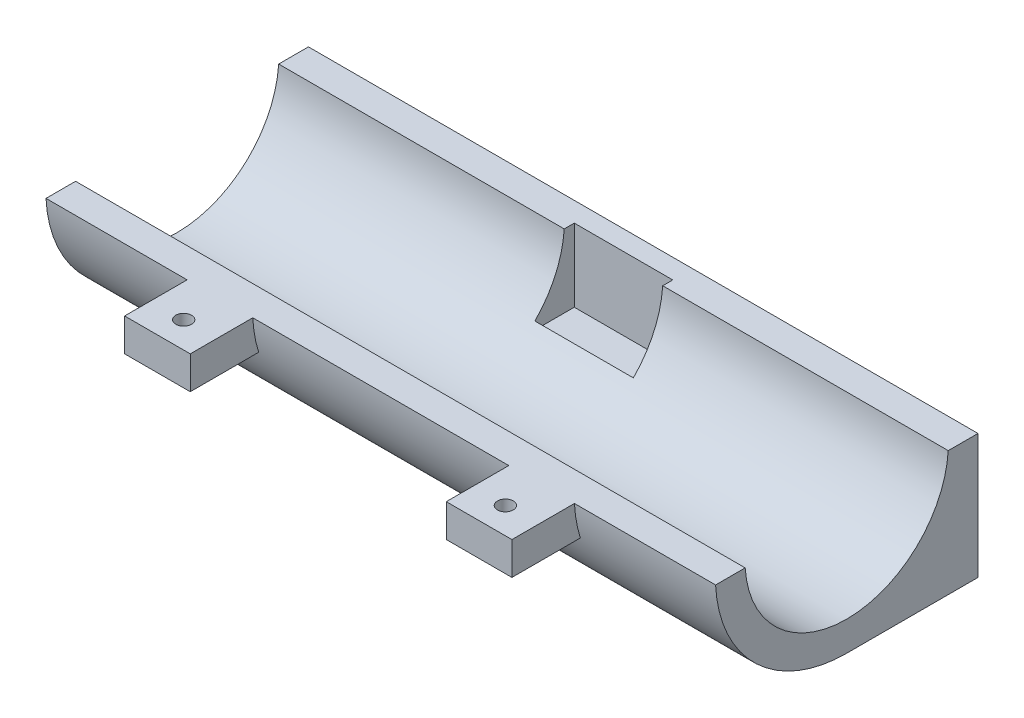
from build123d import *
from build123d.topology import SkipClean

# Parameters (mm, degrees)
SKETCH1_W                = 34
SKETCH1_H                = 30
BOSS_EXTRUDE2_DEPTH      = 51
SKETCH3_R                = 2.55
CUT_EXTRUDE3_DEPTH       = 10
SKETCH5_R                = 7.75
CUT_EXTRUDE4_DEPTH       = 51
SKETCH6_W                = 7
SKETCH6_H                = 30
CUT_EXTRUDE6_DEPTH       = 51
CUT_EXTRUDE7_DEPTH       = 51
CUT_EXTRUDE9_DEPTH       = 1.5
CUT_EXTRUDE9_DEPTH_BACK  = 1.5
BOSS_EXTRUDE5_DEPTH      = 51
CUT_EXTRUDE10_DEPTH      = 13
CUT_EXTRUDE11_START      = -13
CUT_EXTRUDE11_DEPTH      = 13
SKETCH13_W               = 2
SKETCH13_H               = 6
CUT_EXTRUDE12_DEPTH      = 2
CUT_EXTRUDE13_DEPTH      = 13
CUT_EXTRUDE13_DEPTH_BACK = 11
BOSS_EXTRUDE6_DEPTH      = 2.25
BOSS_EXTRUDE7_DEPTH      = 2.25
BOSS_EXTRUDE8_DEPTH      = 2.25
BOSS_EXTRUDE9_DEPTH      = 2.25
SKETCH22_W               = 5
SKETCH22_H               = 6
BOSS_EXTRUDE10_DEPTH     = 1
SKETCH24_W               = 5
SKETCH24_H               = 6
BOSS_EXTRUDE11_DEPTH     = 1
SKETCH25_R               = 0.6
CUT_EXTRUDE14_DEPTH      = 20
SKETCH26_R               = 2.55
BOSS_EXTRUDE12_DEPTH     = 1.5
CUT_EXTRUDE16_DEPTH      = 60


with BuildPart() as part:
    # Sketch1 → Boss-Extrude2 (new body)
    with BuildSketch(Plane(origin=(0, 0, 0), x_dir=(0, 0, -1), z_dir=(1, 0, 0))):
        with Locations((-3.945183177, 6.145902028)):
            Rectangle(SKETCH1_W, SKETCH1_H)
    extrude(amount=BOSS_EXTRUDE2_DEPTH)

    # Sketch3 → Cut-Extrude3 (cut)
    with BuildSketch(Plane(origin=(0, 0, -13.054816823), x_dir=(-1, 0, 0), z_dir=(0, 0, -1))):
        with Locations((-25.5, -1.354097972)):
            Circle(SKETCH3_R)
    extrude(amount=-CUT_EXTRUDE3_DEPTH, mode=Mode.SUBTRACT)

    # Sketch5 → Cut-Extrude4 (cut)
    with BuildSketch(Plane(origin=(51, 0, 0), x_dir=(0, 0, -1), z_dir=(1, 0, 0))):
        with Locations((-3.945183177, 1.145902028)):
            Circle(SKETCH5_R)
    extrude(amount=-CUT_EXTRUDE4_DEPTH, mode=Mode.SUBTRACT)

    # Sketch6 → Cut-Extrude6 (cut)
    with BuildSketch(Plane(origin=(51, 0, 0), x_dir=(0, 0, -1), z_dir=(1, 0, 0))):
        with Locations((9.554816823, 6.145902028)):
            Rectangle(SKETCH6_W, SKETCH6_H)
    extrude(amount=-CUT_EXTRUDE6_DEPTH, mode=Mode.SUBTRACT)

    # Sketch7 → Cut-Extrude7 (cut)
    with BuildSketch(Plane(origin=(51, 0, 0), x_dir=(0, 0, -1), z_dir=(1, 0, 0))):
        with BuildLine():
            Line((-3.945183177, -8.854097972), (-20.945183177, -8.854097972))
            Line((-20.945183177, -8.854097972), (-20.945183177, 21.145902028))
            Line((-20.945183177, 21.145902028), (6.054816823, 21.145902028))
            Line((6.054816823, 21.145902028), (6.054816823, 1.145902028))
            ThreePointArc((6.054816823, 1.145902028), (-11.016250989, 8.21696984), (-3.945183177, -8.854097972))
        make_face()
    extrude(amount=-CUT_EXTRUDE7_DEPTH, mode=Mode.SUBTRACT)

    # Sketch8 → Cut-Extrude9 (cut, two sides: drawn at the far end of the back side and taken through both)
    with BuildSketch(Plane(origin=(0, 0, -3.054816823), x_dir=(-1, 0, 0), z_dir=(0, 0, -1)).offset(-CUT_EXTRUDE9_DEPTH_BACK)):
        Polygon((-21.75, -2.180131646), (-21.75, -4.904097972), (-29.25, -4.904097972), (-29.25, -2.180131646), (-29.25, 2.195902028), (-21.75, 2.195902028), align=None)
    extrude(amount=CUT_EXTRUDE9_DEPTH + CUT_EXTRUDE9_DEPTH_BACK, mode=Mode.SUBTRACT)

    # Sketch10 → Boss-Extrude5 (add)
    with BuildSketch(Plane(origin=(51, 0, 0), x_dir=(0, 0, -1), z_dir=(1, 0, 0))):
        Polygon((-17.695183177, 1.145902028), (-17.695183177, 4.145902028), (-11.695183177, 4.145902028), (-11.695183177, 1.145902028), (-11.695183177, -1.854097972), (-17.695183177, -1.854097972), align=None)
    extrude(amount=-BOSS_EXTRUDE5_DEPTH)

    # Sketch11 → Cut-Extrude10 (cut)
    with BuildSketch(Plane(origin=(51, 0, 0), x_dir=(0, 0, -1), z_dir=(1, 0, 0))):
        with BuildLine():
            Line((-13.484575191, -1.854097972), (-17.695183177, -1.854097972))
            Line((-17.695183177, -1.854097972), (-17.695183177, 4.145902028))
            Line((-17.695183177, 4.145902028), (-13.484575191, 4.145902028))
            ThreePointArc((-13.484575191, 4.145902028), (-13.945183177, 1.145902028), (-13.484575191, -1.854097972))
        make_face()
    extrude(amount=-CUT_EXTRUDE10_DEPTH, mode=Mode.SUBTRACT)

    # Sketch12 → Cut-Extrude11 (cut)
    with BuildSketch(Plane.ZY.offset(CUT_EXTRUDE11_START)):
        with BuildLine():
            Line((13.484575191, -1.854097972), (17.695183177, -1.854097972))
            Line((17.695183177, -1.854097972), (17.695183177, 4.145902028))
            Line((17.695183177, 4.145902028), (13.484575191, 4.145902028))
            ThreePointArc((13.484575191, 4.145902028), (13.945183177, 1.145902028), (13.484575191, -1.854097972))
        make_face()
    extrude(amount=CUT_EXTRUDE11_DEPTH, mode=Mode.SUBTRACT)

    # Sketch13 → Cut-Extrude12 (cut)
    with BuildSketch(Plane.XY.offset(17.695183177)):
        with Locations((25.5, 1.145902028)):
            Rectangle(SKETCH13_W, SKETCH13_H)
    extrude(amount=-CUT_EXTRUDE12_DEPTH, mode=Mode.SUBTRACT)

    # Sketch15 → Cut-Extrude13 (cut, two sides: drawn at the far end of the back side and taken through both)
    with SkipClean():  # the faces are left unmerged after this step: merging them gives an invalid solid
        with BuildSketch(Plane(origin=(24.5, 0, 0), x_dir=(0, 0, -1), z_dir=(1, 0, 0)).offset(-CUT_EXTRUDE13_DEPTH_BACK)):
            with BuildLine():
                Line((-17.695183177, 4.145902028), (-17.695183177, -1.854097972))
                Line((-17.695183177, -1.854097972), (-13.484575191, -1.854097972))
                ThreePointArc((-13.484575191, -1.854097972), (-13.945183177, 1.145902028), (-13.484575191, 4.145902028))
                Line((-13.484575191, 4.145902028), (-17.695183177, 4.145902028))
            make_face()
        extrude(amount=CUT_EXTRUDE13_DEPTH + CUT_EXTRUDE13_DEPTH_BACK, mode=Mode.SUBTRACT)

    # Sketch17 → Boss-Extrude6 (add)
    with SkipClean():  # the faces are left unmerged after this step: merging them gives an invalid solid
        with BuildSketch(Plane(origin=(38, 0, 0), x_dir=(0, 0, -1), z_dir=(1, 0, 0))):
            with BuildLine():
                Line((-13.484575191, 4.145902028), (-17.695183177, 4.145902028))
                Line((-17.695183177, 4.145902028), (-17.695183177, -1.854097972))
                Line((-17.695183177, -1.854097972), (-13.484575191, -1.854097972))
                ThreePointArc((-13.484575191, -1.854097972), (-13.945183177, 1.145902028), (-13.484575191, 4.145902028))
            make_face()
        extrude(amount=BOSS_EXTRUDE6_DEPTH)

    # Sketch19 → Boss-Extrude7 (add)
    with SkipClean():  # the faces are left unmerged after this step: merging them gives an invalid solid
        with BuildSketch(Plane.ZY.offset(-13)):
            with BuildLine():
                Line((13.484575191, 4.145902028), (17.695183177, 4.145902028))
                Line((17.695183177, 4.145902028), (17.695183177, -1.854097972))
                Line((17.695183177, -1.854097972), (13.484575191, -1.854097972))
                ThreePointArc((13.484575191, -1.854097972), (13.945183177, 1.145902028), (13.484575191, 4.145902028))
            make_face()
        extrude(amount=BOSS_EXTRUDE7_DEPTH)

    # Sketch20 → Boss-Extrude8 (add)
    with SkipClean():  # the faces are left unmerged after this step: merging them gives an invalid solid
        with BuildSketch(Plane(origin=(13.5, 0, 0), x_dir=(0, 0, -1), z_dir=(1, 0, 0))):
            with BuildLine():
                Line((-17.695183177, -1.854097972), (-17.695183177, 4.145902028))
                Line((-17.695183177, 4.145902028), (-13.484575191, 4.145902028))
                ThreePointArc((-13.484575191, 4.145902028), (-13.945183177, 1.145902028), (-13.484575191, -1.854097972))
                Line((-13.484575191, -1.854097972), (-17.695183177, -1.854097972))
            make_face()
        extrude(amount=BOSS_EXTRUDE8_DEPTH)

    # Sketch21 → Boss-Extrude9 (add)
    with SkipClean():  # the faces are left unmerged after this step: merging them gives an invalid solid
        with BuildSketch(Plane.ZY.offset(-37.5)):
            with BuildLine():
                Line((13.484575191, 4.145902028), (17.695183177, 4.145902028))
                Line((17.695183177, 4.145902028), (17.695183177, -1.854097972))
                Line((17.695183177, -1.854097972), (13.484575191, -1.854097972))
                ThreePointArc((13.484575191, -1.854097972), (13.945183177, 1.145902028), (13.484575191, 4.145902028))
            make_face()
        extrude(amount=BOSS_EXTRUDE9_DEPTH)

    # Sketch22 → Boss-Extrude10 (add)
    with SkipClean():  # the faces are left unmerged after this step: merging them gives an invalid solid
        with BuildSketch(Plane.XY.offset(17.695183177)):
            with Locations((37.75, 1.145902028)):
                Rectangle(SKETCH22_W, SKETCH22_H)
        extrude(amount=BOSS_EXTRUDE10_DEPTH)

    # Sketch24 → Boss-Extrude11 (add)
    with SkipClean():  # the faces are left unmerged after this step: merging them gives an invalid solid
        with BuildSketch(Plane.XY.offset(17.695183177)):
            with Locations((13.25, 1.145902028)):
                Rectangle(SKETCH24_W, SKETCH24_H)
        extrude(amount=BOSS_EXTRUDE11_DEPTH)

    # Sketch25 → Cut-Extrude14 (cut)
    with SkipClean():  # the faces are left unmerged after this step: merging them gives an invalid solid
        with BuildSketch(Plane(origin=(0, 4.145902028, 0), x_dir=(1, 0, 0), z_dir=(0, 1, 0))):
            with Locations((13.25, -16.695183177)):
                Circle(SKETCH25_R)
            with Locations((37.75, -16.695183177)):
                Circle(SKETCH25_R)
        extrude(amount=-CUT_EXTRUDE14_DEPTH, mode=Mode.SUBTRACT)

    # Sketch26 → Boss-Extrude12 (add)
    with SkipClean():  # the faces are left unmerged after this step: merging them gives an invalid solid
        with BuildSketch(Plane(origin=(0, 0, -6.054816823), x_dir=(-1, 0, 0), z_dir=(0, 0, -1))):
            with Locations((-25.5, -1.354097972)):
                Circle(SKETCH26_R)
        extrude(amount=-BOSS_EXTRUDE12_DEPTH)

    # Sketch27 → Cut-Extrude16 (cut)
    with SkipClean():  # the faces are left unmerged after this step: merging them gives an invalid solid
        with BuildSketch(Plane(origin=(51, 0, 0), x_dir=(0, 0, -1), z_dir=(1, 0, 0))):
            Polygon((-18.695183177, 1.145902028), (-18.695183177, 12.015935401), (6.594766684, 12.015935401), (6.594766684, 1.145902028), (6.594766684, 0.645902028), (-18.695183177, 0.645902028), align=None)
        extrude(amount=-CUT_EXTRUDE16_DEPTH, mode=Mode.SUBTRACT)


solid = part.part
